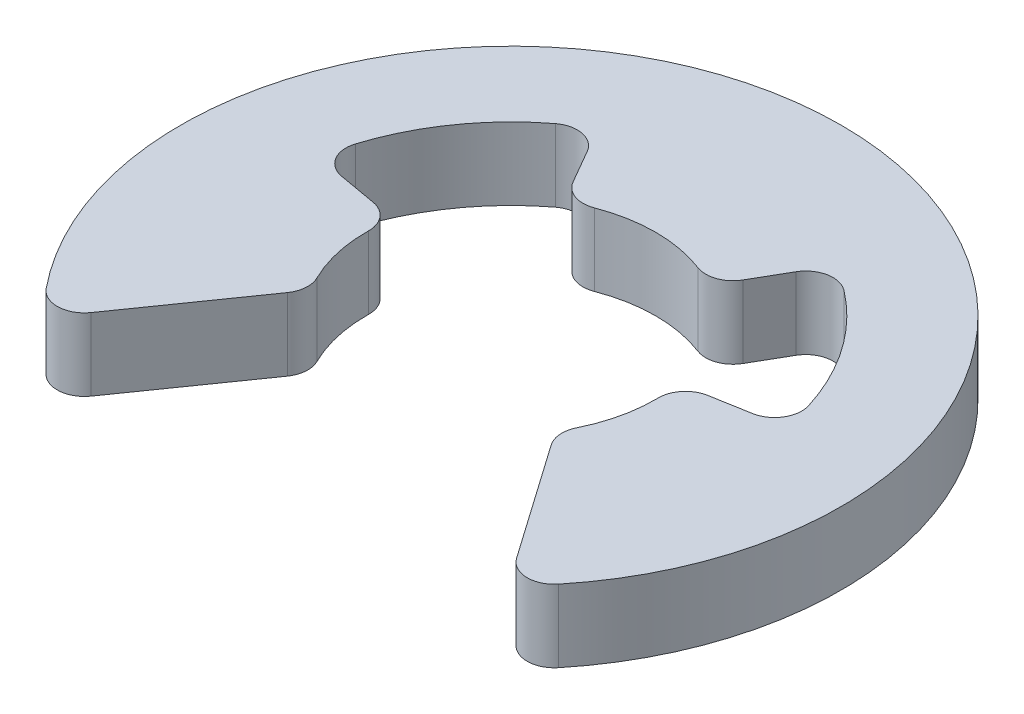
from build123d import *

# Parameters (mm, degrees)
SKETCH4_W                 = 2.05
SKETCH4_H                 = 0.8
SKETCH5_OUTSIDE_W         = 11.37
SKETCH5_OUTSIDE_H         = 11.37
CUT_INNER_BODY_DEPTH      = 1.5
CUT_INNER_BODY_DEPTH_BACK = 1.3
FILLET_2_R                = 0.3


with BuildPart() as part:
    # Sketch4 → Clip (revolve)
    with BuildSketch(Plane.XY):
        with Locations((2.625, 0.1)):
            Rectangle(SKETCH4_W, SKETCH4_H)
    revolve(axis=Axis((0, 0.5, 0), (0, -1, 0)))

    # Sketch5 outside → Cut-Inner-Body (cut, two sides)
    with BuildSketch(Plane(origin=(0, 0, 0), x_dir=(1, 0, 0), z_dir=(0, 1, 0))) as cut_inner_body_sk:
        Rectangle(SKETCH5_OUTSIDE_W, SKETCH5_OUTSIDE_H)
        with BuildLine():
            Line((2.566160275, -2.595635075), (1.35, -0.858778202))
            ThreePointArc((1.35, -0.858778202), (1.569360567, -0.31162062), (1.575692405, 0.277837084))
            Line((1.575692405, 0.277837084), (2.585120352, 0.455826466))
            ThreePointArc((2.585120352, 0.455826466), (2.150274116, 1.505638145), (1.3125, 2.273316685))
            Line((1.3125, 2.273316685), (0.8, 1.385640646))
            ThreePointArc((0.8, 1.385640646), (0, 1.6), (-0.8, 1.385640646))
            Line((-0.8, 1.385640646), (-1.3125, 2.273316685))
            ThreePointArc((-1.3125, 2.273316685), (-2.150274116, 1.505638145), (-2.585120352, 0.455826466))
            Line((-2.585120352, 0.455826466), (-1.575692405, 0.277837084))
            ThreePointArc((-1.575692405, 0.277837084), (-1.569360567, -0.31162062), (-1.35, -0.858778202))
            Line((-1.35, -0.858778202), (-2.566160275, -2.595635075))
            ThreePointArc((-2.566160275, -2.595635075), (0, 3.65), (2.566160275, -2.595635075))
        make_face(mode=Mode.SUBTRACT)
    extrude(amount=CUT_INNER_BODY_DEPTH, mode=Mode.SUBTRACT)
    extrude(cut_inner_body_sk.sketch, amount=-CUT_INNER_BODY_DEPTH_BACK, mode=Mode.SUBTRACT)

    # Fillet 2
    fillet_2_edges = [part.edges().sort_by_distance(p)[0] for p in [
        (2.566160275, 0.1, 2.595635075),
        (1.35, 0.1, 0.858778202),
        (1.575692405, 0.1, -0.277837084),
        (2.585120352, 0.1, -0.455826466),
        (1.3125, 0.1, -2.273316685),
        (0.8, 0.1, -1.385640646),
        (-0.8, 0.1, -1.385640646),
        (-1.3125, 0.1, -2.273316685),
        (-2.585120352, 0.1, -0.455826466),
        (-1.575692405, 0.1, -0.277837084),
        (-1.35, 0.1, 0.858778202),
        (-2.566160275, 0.1, 2.595635075),
    ]]
    fillet(fillet_2_edges, radius=FILLET_2_R)


solid = part.part
